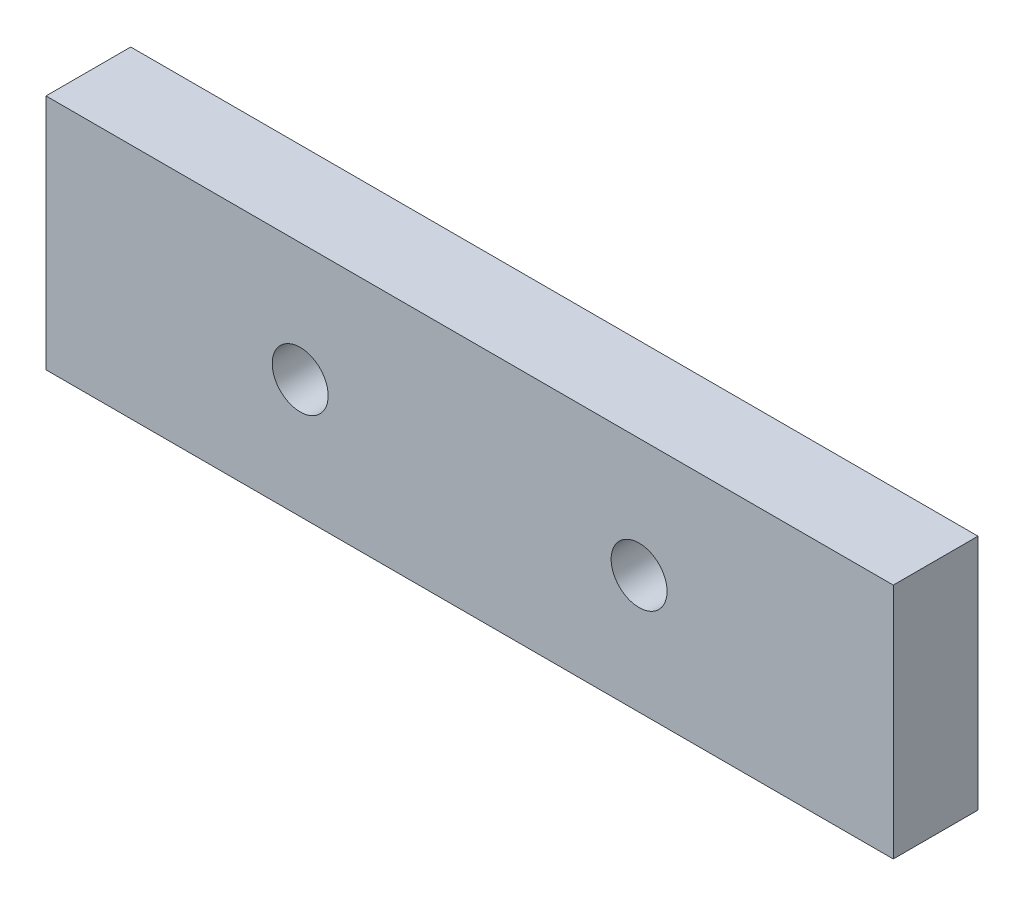
from build123d import *

# Parameters (mm, degrees)
SKETCH1_W             = 50
SKETCH1_H             = 14
BOSS_EXTRUDE1_DEPTH   = 2.5
M4X0_7_TAPPED_HOLE1_D = 3.3


with BuildPart() as part:
    # Sketch1 → Boss-Extrude1 (new body, symmetric)
    with BuildSketch(Plane.XY):
        Rectangle(SKETCH1_W, SKETCH1_H)
    extrude(amount=BOSS_EXTRUDE1_DEPTH, both=True)

    # M4x0.7 Tapped Hole1 (through all)
    with Locations(Plane.XY.offset(2.5)):
        with Locations((-10, 0), (10, 0)):
            Hole(M4X0_7_TAPPED_HOLE1_D / 2)


solid = part.part
